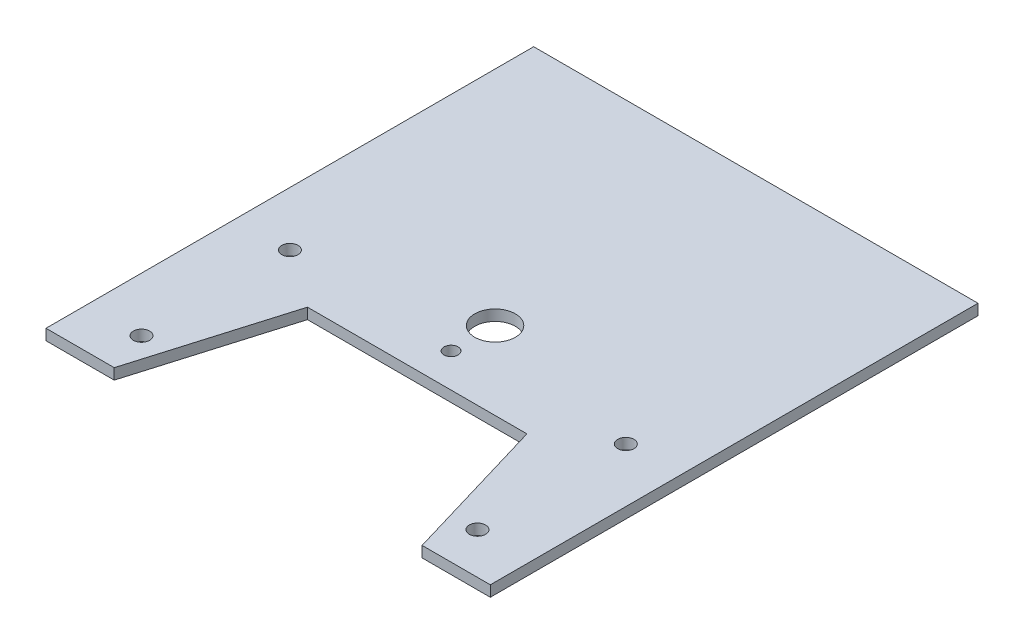
from build123d import *

# Parameters (mm, degrees)
BOSS_EXTRUDE3_DEPTH = 4
CUT_EXTRUDE3_REACH  = 6
SKETCH5_R           = 3
SKETCH5_R_2         = 7.5
SKETCH5_R_3         = 2.6


with BuildPart() as part:
    # Sketch1 → Boss-Extrude3 (new body)
    with BuildSketch(Plane(origin=(0, 0, 0), x_dir=(1, 0, 0), z_dir=(0, 1, 0))):
        Polygon((40.5, -35), (56.816666667, -90), (82, -90), (82, 90), (-82, 90), (-82, -90), (-56.816666667, -90), (-40.5, -35), align=None)
    extrude(amount=BOSS_EXTRUDE3_DEPTH)

    # Sketch5 → Cut-Extrude3 (cut, up to next)
    with BuildSketch(Plane(origin=(0, 4, 0), x_dir=(1, 0, 0), z_dir=(0, 1, 0)), mode=Mode.PRIVATE) as cut_extrude3_sk1:
        with Locations((62, -74.75)):
            Circle(SKETCH5_R)
    cut_extrude3_tool1 = extrude(cut_extrude3_sk1.sketch, amount=-CUT_EXTRUDE3_REACH, mode=Mode.PRIVATE) & part.part
    add(cut_extrude3_tool1.solids().sort_by_distance((62, 4, 74.75))[0], mode=Mode.SUBTRACT)
    # Sketch5 → Cut-Extrude3 (cut, up to next)
    with BuildSketch(Plane(origin=(0, 4, 0), x_dir=(1, 0, 0), z_dir=(0, 1, 0)), mode=Mode.PRIVATE) as cut_extrude3_sk2:
        with Locations((62, -19.99)):
            Circle(SKETCH5_R)
    cut_extrude3_tool2 = extrude(cut_extrude3_sk2.sketch, amount=-CUT_EXTRUDE3_REACH, mode=Mode.PRIVATE) & part.part
    add(cut_extrude3_tool2.solids().sort_by_distance((62, 4, 19.99))[0], mode=Mode.SUBTRACT)
    # Sketch5 → Cut-Extrude3 (cut, up to next)
    with BuildSketch(Plane(origin=(0, 4, 0), x_dir=(1, 0, 0), z_dir=(0, 1, 0)), mode=Mode.PRIVATE) as cut_extrude3_sk3:
        with Locations((-62, -74.75)):
            Circle(SKETCH5_R)
    cut_extrude3_tool3 = extrude(cut_extrude3_sk3.sketch, amount=-CUT_EXTRUDE3_REACH, mode=Mode.PRIVATE) & part.part
    add(cut_extrude3_tool3.solids().sort_by_distance((-62, 4, 74.75))[0], mode=Mode.SUBTRACT)
    # Sketch5 → Cut-Extrude3 (cut, up to next)
    with BuildSketch(Plane(origin=(0, 4, 0), x_dir=(1, 0, 0), z_dir=(0, 1, 0)), mode=Mode.PRIVATE) as cut_extrude3_sk4:
        with Locations((-62, -19.99)):
            Circle(SKETCH5_R)
    cut_extrude3_tool4 = extrude(cut_extrude3_sk4.sketch, amount=-CUT_EXTRUDE3_REACH, mode=Mode.PRIVATE) & part.part
    add(cut_extrude3_tool4.solids().sort_by_distance((-62, 4, 19.99))[0], mode=Mode.SUBTRACT)
    # Sketch5 → Cut-Extrude3 (cut, up to next)
    with BuildSketch(Plane(origin=(0, 4, 0), x_dir=(1, 0, 0), z_dir=(0, 1, 0)), mode=Mode.PRIVATE) as cut_extrude3_sk5:
        with Locations((0, -6.25)):
            Circle(SKETCH5_R_2)
    cut_extrude3_tool5 = extrude(cut_extrude3_sk5.sketch, amount=-CUT_EXTRUDE3_REACH, mode=Mode.PRIVATE) & part.part
    add(cut_extrude3_tool5.solids().sort_by_distance((0, 4, 6.25))[0], mode=Mode.SUBTRACT)
    # Sketch5 → Cut-Extrude3 (cut, up to next)
    with BuildSketch(Plane(origin=(0, 4, 0), x_dir=(1, 0, 0), z_dir=(0, 1, 0)), mode=Mode.PRIVATE) as cut_extrude3_sk6:
        with Locations((0, -22.5)):
            Circle(SKETCH5_R_3)
    cut_extrude3_tool6 = extrude(cut_extrude3_sk6.sketch, amount=-CUT_EXTRUDE3_REACH, mode=Mode.PRIVATE) & part.part
    add(cut_extrude3_tool6.solids().sort_by_distance((0, 4, 22.5))[0], mode=Mode.SUBTRACT)


solid = part.part
